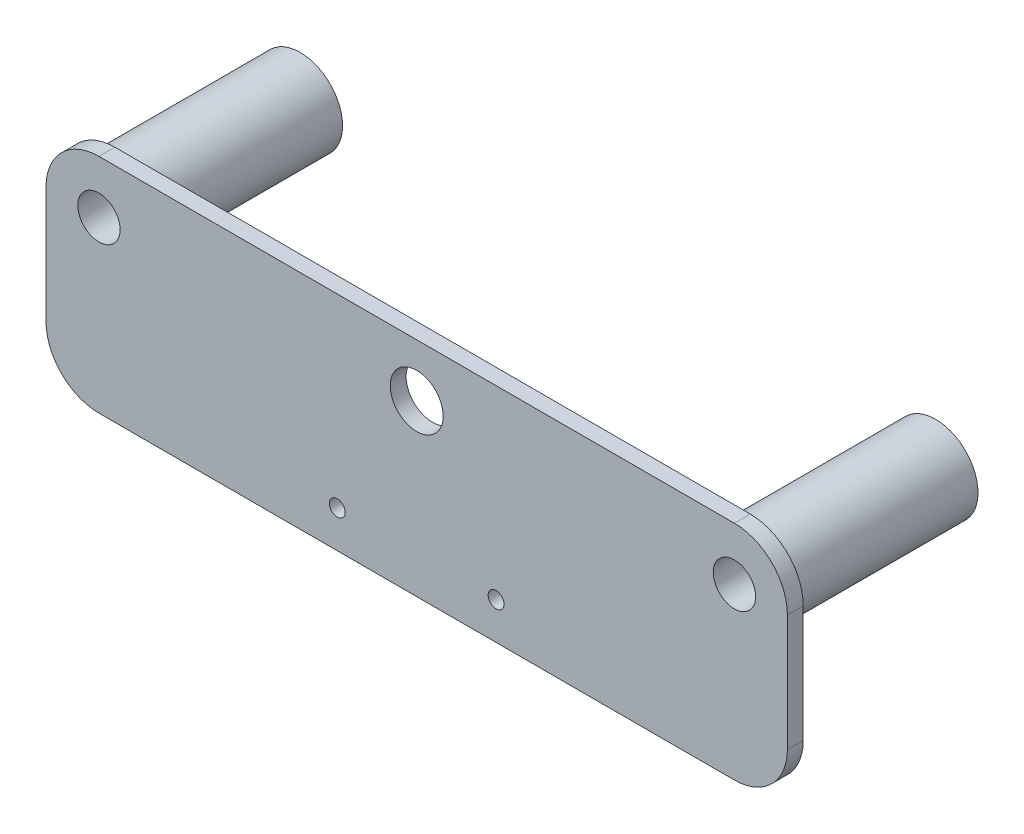
from build123d import *

# Parameters (mm, degrees)
ESQUISSE1_W        = 140
ESQUISSE1_H        = 42
ESQUISSE1_R        = 5
ESQUISSE1_R_2      = 4
ESQUISSE1_R_3      = 1.5
BOSS_EXTRU_1_DEPTH = 3
CONG_1_R           = 10
CONG_2_R           = 10
ESQUISSE2_R        = 8
ESQUISSE2_R_2      = 4
BOSS_EXTRU_2_DEPTH = 38


with BuildPart() as part:
    # Esquisse1 → Boss.-Extru.1 (new body)
    with BuildSketch(Plane.XY):
        with Locations((-70, 21)):
            Rectangle(ESQUISSE1_W, ESQUISSE1_H)
        with Locations((-70, 32)):
            Circle(ESQUISSE1_R, mode=Mode.SUBTRACT)
        with Locations((-130, 32)):
            Circle(ESQUISSE1_R_2, mode=Mode.SUBTRACT)
        with Locations((-55, 7)):
            Circle(ESQUISSE1_R_3, mode=Mode.SUBTRACT)
        with Locations((-10, 32)):
            Circle(ESQUISSE1_R_2, mode=Mode.SUBTRACT)
        with Locations((-85, 7)):
            Circle(ESQUISSE1_R_3, mode=Mode.SUBTRACT)
    extrude(amount=BOSS_EXTRU_1_DEPTH)

    # Congé1
    cong_1_edges = [part.edges().sort_by_distance(p)[0] for p in [
        (-140, 42, 1.5),
        (0, 42, 1.5),
    ]]
    fillet(cong_1_edges, radius=CONG_1_R)

    # Congé2
    cong_2_edges = [part.edges().sort_by_distance(p)[0] for p in [
        (0, 0, 1.5),
        (-140, 0, 1.5),
    ]]
    fillet(cong_2_edges, radius=CONG_2_R)

    # Esquisse2 → Boss.-Extru.2 (add)
    with BuildSketch(Plane.XY.offset(3)):
        with Locations((-10, 32)):
            Circle(ESQUISSE2_R)
        with Locations((-10, 32)):
            Circle(ESQUISSE2_R_2, mode=Mode.SUBTRACT)
        with Locations((-130, 32)):
            Circle(ESQUISSE2_R)
        with Locations((-130, 32)):
            Circle(ESQUISSE2_R_2, mode=Mode.SUBTRACT)
    extrude(amount=-BOSS_EXTRU_2_DEPTH)


solid = part.part
